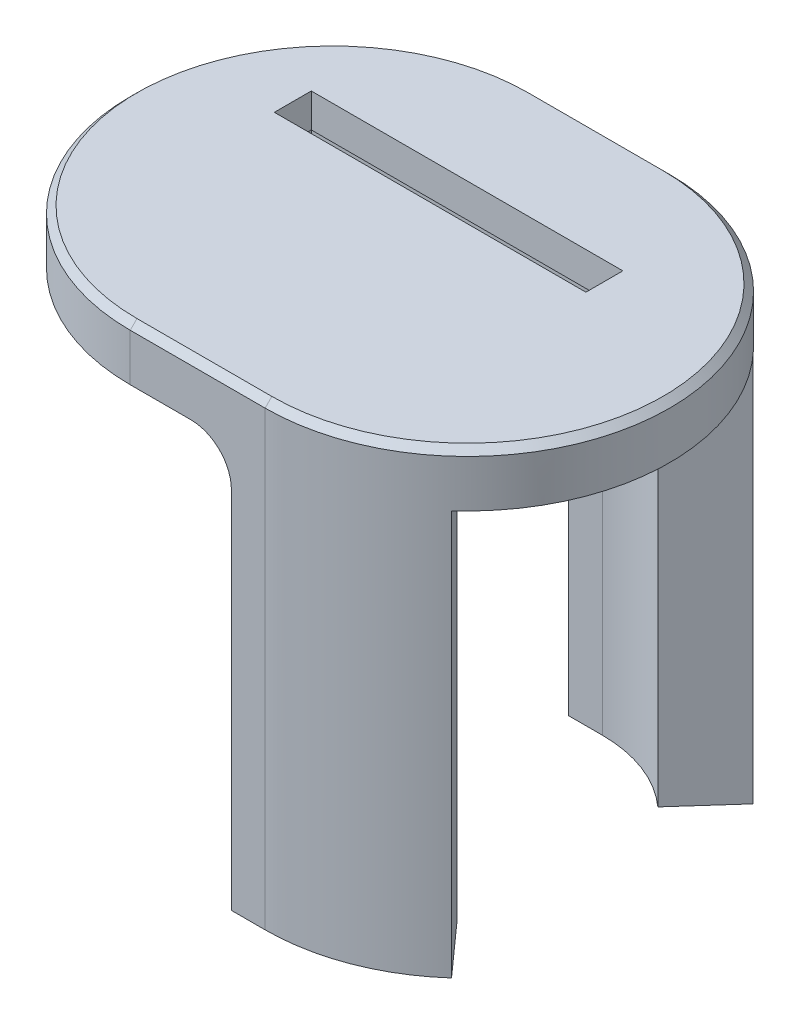
from build123d import *

# Parameters (mm, degrees)
AUFSATZ_LINEAR_AUSTRAGEN1_DEPTH   = 30
AUFSATZ_LINEAR_AUSTRAGEN1_2_DEPTH = 30
AUFSATZ_LINEAR_START              = 4
AUFSATZ_LINEAR_AUSTRAGEN2_DEPTH   = 4
VERRUNDUNG1_R                     = 3
VERRUNDUNG2_R                     = 3
FASE1_SIZE                        = 0.5
SKIZZE3_R                         = 1.25
SCHNITT_LINEAR_AUSTRAGEN1_DEPTH   = 8
SKIZZE4_W                         = 23.1
SKIZZE4_H                         = 2.74
SCHNITT_LINEAR_AUSTRAGEN2_DEPTH   = 2.5
SCHNITT_LINEAR_AUSTRAGEN3_REACH   = 42.215
SKIZZE5_W                         = 23.5
SKIZZE5_H                         = 3.14


with BuildPart() as part:
    # Skizze1 → Aufsatz-Linear austragen1 (new body)
    with BuildSketch(Plane(origin=(0, 0, 0), x_dir=(1, 0, 0), z_dir=(0, 1, 0))):
        with BuildLine():
            Line((5, 15), (2.5, 15))
            Line((2.5, 15), (2.5, 10))
            Line((2.5, 10), (5, 10))
            ThreePointArc((5, 10), (8.568220898, 9.34172359), (11.666666667, 7.453559925))
            Line((11.666666667, 7.453559925), (15, 11.180339887))
            ThreePointArc((15, 11.180339887), (10.352331347, 14.012585384), (5, 15))
        make_face()
    extrude(amount=-AUFSATZ_LINEAR_AUSTRAGEN1_DEPTH)



with BuildPart() as body_2:
    # Skizze1 → Aufsatz-Linear austragen1 2 (new body)
    with BuildSketch(Plane(origin=(0, 0, 0), x_dir=(1, 0, 0), z_dir=(0, 1, 0))):
        with BuildLine():
            Line((11.666666667, -7.453559925), (15, -11.180339887))
            ThreePointArc((15, -11.180339887), (10.352331347, -14.012585384), (5, -15))
            Line((5, -15), (2.5, -15))
            Line((2.5, -15), (2.5, -10))
            Line((2.5, -10), (5, -10))
            ThreePointArc((5, -10), (8.568220898, -9.34172359), (11.666666667, -7.453559925))
        make_face()
    extrude(amount=-AUFSATZ_LINEAR_AUSTRAGEN1_2_DEPTH)


with BuildPart() as part_1:
    add(part.part)

    add(body_2.part)  # Aufsatz-Linear austragen2 merges body 2
    # Skizze2 → Aufsatz-Linear austragen2 (add)
    with BuildSketch(Plane(origin=(0, 0, 0), x_dir=(1, 0, 0), z_dir=(0, 1, 0)).offset(AUFSATZ_LINEAR_START)):
        with BuildLine():
            Line((-5, 15), (5, 15))
            ThreePointArc((5, 15), (20, 0), (5, -15))
            Line((5, -15), (-5, -15))
            ThreePointArc((-5, -15), (-20, 0), (-5, 15))
        make_face()
    extrude(amount=-AUFSATZ_LINEAR_AUSTRAGEN2_DEPTH)

    # Verrundung1
    verrundung1_edges = [part_1.edges().sort_by_distance(p)[0] for p in [
        (3.75, 0, 10),
        (8.568220898, 0, 9.34172359),
        (8.568220898, 0, -9.34172359),
        (3.75, 0, -10),
    ]]
    fillet(verrundung1_edges, radius=VERRUNDUNG1_R)

    # Verrundung2
    verrundung2_edges = [part_1.edges().sort_by_distance(p)[0] for p in [
        (2.5, 0, 11),
        (2.5, 0, -11),
    ]]
    fillet(verrundung2_edges, radius=VERRUNDUNG2_R)

    # Fase1
    fase1_edges = [part_1.edges().sort_by_distance(p)[0] for p in [
        (-20, 4, 0),
        (0, 4, 15),
        (0, 4, -15),
        (20, 4, 0),
    ]]
    chamfer(fase1_edges, length=FASE1_SIZE)

    # Skizze3 → Schnitt-Linear austragen1 (cut)
    with BuildSketch(Plane.XZ.offset(30)):
        with Locations((9.644187298, -11.605236936)):
            Circle(SKIZZE3_R)
        with Locations((9.644187298, 11.605236936)):
            Circle(SKIZZE3_R)
    extrude(amount=-SCHNITT_LINEAR_AUSTRAGEN1_DEPTH, mode=Mode.SUBTRACT)

    # Skizze4 → Schnitt-Linear austragen2 (cut)
    with BuildSketch(Plane(origin=(0, 4, 0), x_dir=(1, 0, 0), z_dir=(0, 1, 0))):
        with Locations((-1.602471757, 5.205199937)):
            Rectangle(SKIZZE4_W, SKIZZE4_H)
    extrude(amount=-SCHNITT_LINEAR_AUSTRAGEN2_DEPTH, mode=Mode.SUBTRACT)

    # Skizze5 → Schnitt-Linear austragen3 (cut, up to next)
    with BuildSketch(Plane(origin=(0, 1.5, 0), x_dir=(1, 0, 0), z_dir=(0, 1, 0)), mode=Mode.PRIVATE) as schnitt_linear_austragen3_sk1:
        with Locations((-1.602471757, 5.205199937)):
            Rectangle(SKIZZE5_W, SKIZZE5_H)
    schnitt_linear_austragen3_tool1 = extrude(schnitt_linear_austragen3_sk1.sketch, amount=-SCHNITT_LINEAR_AUSTRAGEN3_REACH, mode=Mode.PRIVATE) & part_1.part
    add(schnitt_linear_austragen3_tool1.solids().sort_by_distance((-1.602472, 1.5, -5.2052))[0], mode=Mode.SUBTRACT)


solid = part_1.part
